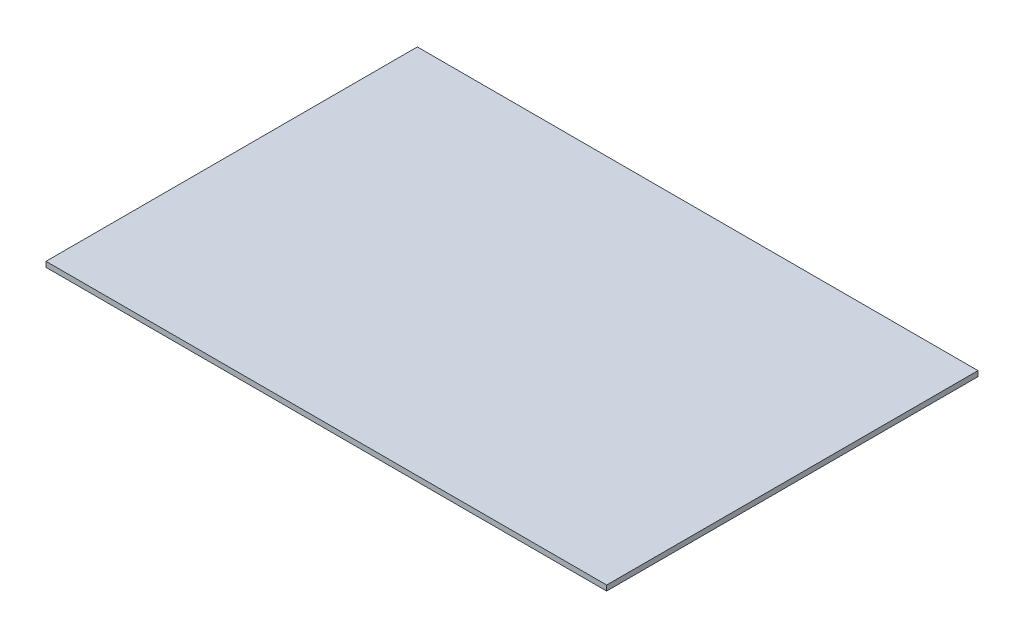
from build123d import *

# Parameters (mm, degrees)
SKETCH1_W           = 168.8
SKETCH1_H           = 111.8
BOSS_EXTRUDE1_DEPTH = 1.5875


with BuildPart() as part:
    # Sketch1 → Boss-Extrude1 (new body)
    with BuildSketch(Plane(origin=(0, 0, 0), x_dir=(1, 0, 0), z_dir=(0, 1, 0))):
        Rectangle(SKETCH1_W, SKETCH1_H)
    extrude(amount=BOSS_EXTRUDE1_DEPTH)


solid = part.part
